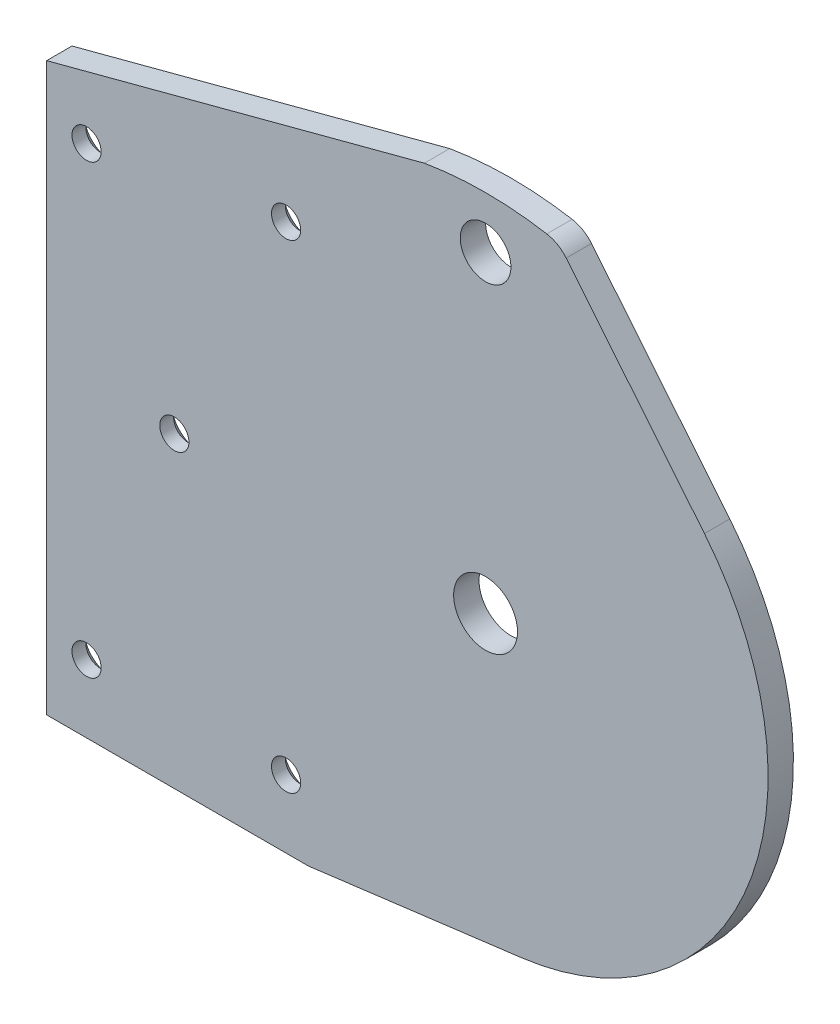
from build123d import *

# Parameters (mm, degrees)
SKETCH1_R                                         = 3.175
SKETCH1_R_2                                       = 4
BOSS_EXTRUDE1_DEPTH                               = 3.175
CSK_FOR_6_FLAT_HEAD_MACHINE_SCREW_100_D           = 3.6576
CSK_FOR_6_FLAT_HEAD_MACHINE_SCREW_100_DEPTH       = 8
CSK_FOR_6_FLAT_HEAD_MACHINE_SCREW_100_CSINK_D     = 7.0866
CSK_FOR_6_FLAT_HEAD_MACHINE_SCREW_100_CSINK_ANGLE = 100
CSK_FOR_6_FLAT_HEAD_MACHINE_SCREW_100_TIP         = 1.0988539


with BuildPart() as part:
    # Sketch1 → Boss-Extrude1 (new body)
    with BuildSketch(Plane.XY):
        with BuildLine():
            Line((-55, -38.509768834), (-22.199103684, -38.509768834))
            Line((-22.199103684, -38.509768834), (4.467936384, -35.116912513))
            ThreePointArc((4.467936384, -35.116912513), (32.876567079, -13.125979473), (27.425045484, 22.383629737))
            Line((27.425045484, 22.383629737), (10.098875196, 43.612135293))
            ThreePointArc((10.098875196, 43.612135293), (9.013562327, 44.539147516), (7.671865627, 45.026082472))
            ThreePointArc((7.671865627, 45.026082472), (0, 45.675), (-7.671865627, 45.026082472))
            Line((-7.671865627, 45.026082472), (-55, 32.491174512))
            Line((-55, 32.491174512), (-55, -38.509768834))
        make_face()
        with Locations((0, 39.175)):
            Circle(SKETCH1_R, mode=Mode.SUBTRACT)
        Circle(SKETCH1_R_2, mode=Mode.SUBTRACT)
    extrude(amount=-BOSS_EXTRUDE1_DEPTH)

    # CSK for _6 Flat Head Machine Screw _100
    with Locations(Plane(origin=(0, 0, -3.175), x_dir=(-1, 0, 0), z_dir=(0, 0, -1))):
        with Locations((50, 26), (39, 0), (50, -30), (25, 30), (25, -30)):
            CounterSinkHole(CSK_FOR_6_FLAT_HEAD_MACHINE_SCREW_100_D / 2, CSK_FOR_6_FLAT_HEAD_MACHINE_SCREW_100_CSINK_D / 2, depth=CSK_FOR_6_FLAT_HEAD_MACHINE_SCREW_100_DEPTH, counter_sink_angle=CSK_FOR_6_FLAT_HEAD_MACHINE_SCREW_100_CSINK_ANGLE)
            with Locations((0, 0, -(CSK_FOR_6_FLAT_HEAD_MACHINE_SCREW_100_DEPTH + CSK_FOR_6_FLAT_HEAD_MACHINE_SCREW_100_TIP / 2))):  # 118° drill point
                Cone(0, CSK_FOR_6_FLAT_HEAD_MACHINE_SCREW_100_D / 2, CSK_FOR_6_FLAT_HEAD_MACHINE_SCREW_100_TIP, mode=Mode.SUBTRACT)


solid = part.part
